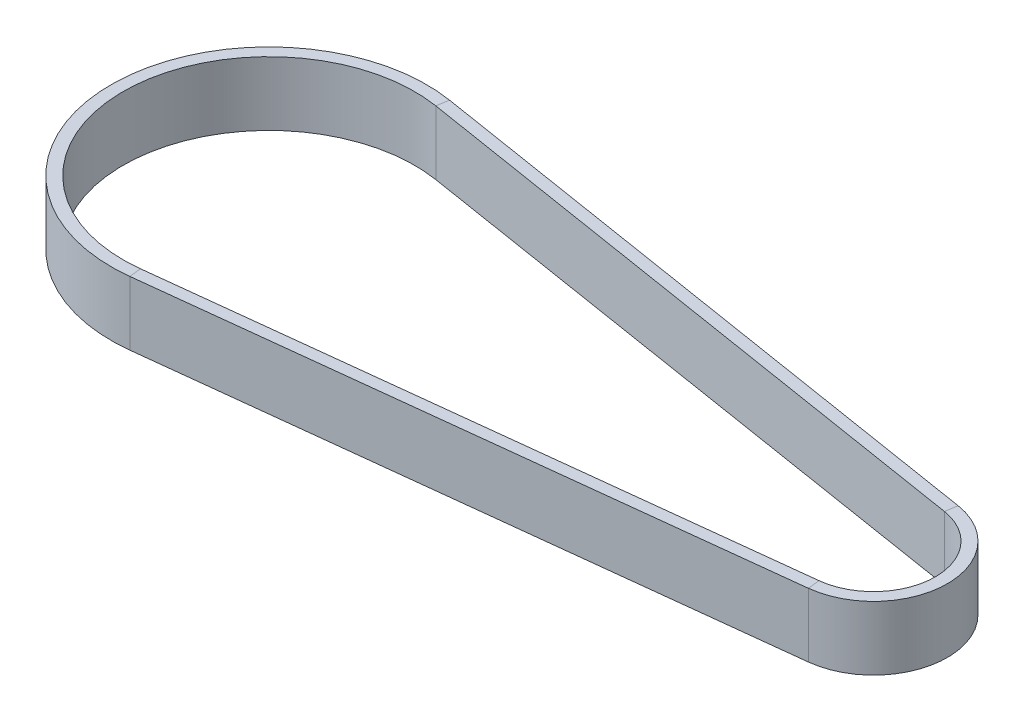
from build123d import *

# Parameters (mm, degrees)
SKETCH2_W = 3
SKETCH2_H = 16


with BuildPart() as part:
    # Sweep1: sweep along a path in Sketch1
    with BuildLine(Plane(origin=(0, 0, 0), x_dir=(1, 0, 0), z_dir=(0, 1, 0))) as sweep1_path:
        Line((245.758880733, 4211.459877414), (397.398524449, 4187.181935703))
        ThreePointArc((397.398524449, 4187.181935703), (411.706562996, 4170.007234672), (396.62872885, 4153.504227672))
        Line((396.62872885, 4153.504227672), (244.038161159, 4136.180294755))
        ThreePointArc((244.038161159, 4136.180294755), (201.761401419, 4174.806102256), (245.758880733, 4211.459877414))
    # Sketch2 → Sweep1 (sweep)
    with BuildSketch(Plane(origin=(244.038161159, 0, -4136.180294755), x_dir=(0.11280744431470559, 0, 0.993616868066955), z_dir=(-0.993616868066955, 0, 0.11280744431470559))):
        Rectangle(SKETCH2_W, SKETCH2_H)
    sweep(path=sweep1_path.line)


solid = part.part
